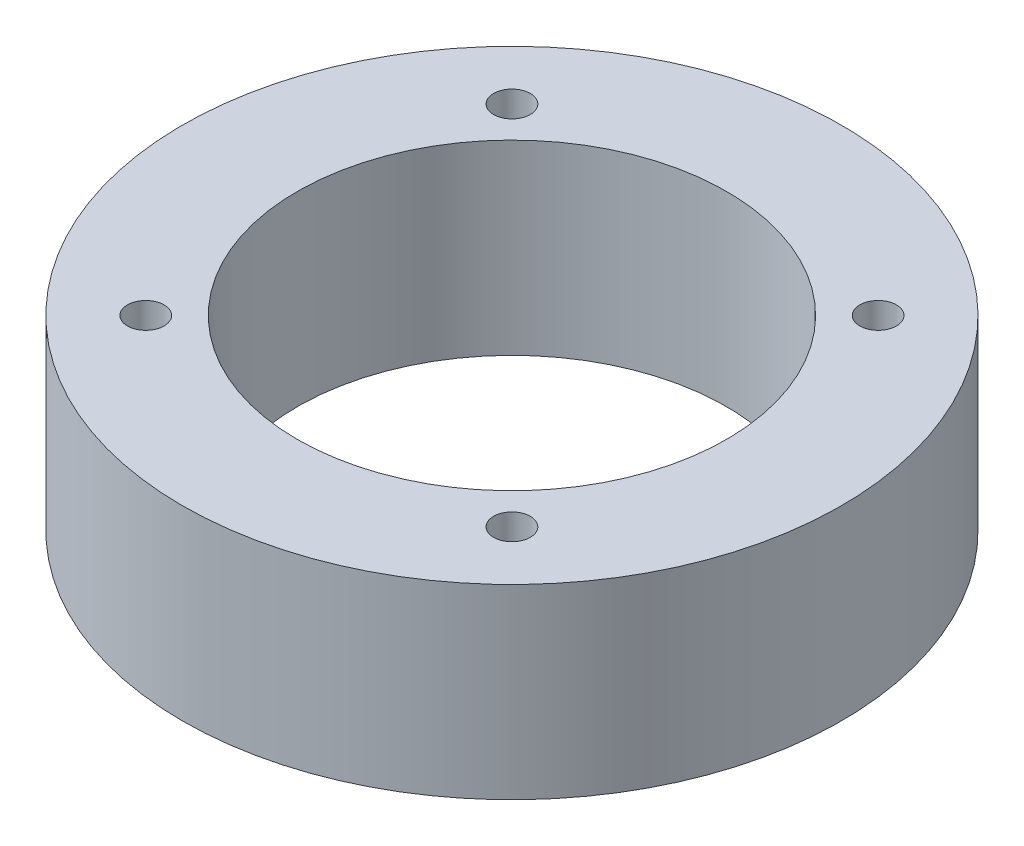
from build123d import *

# Parameters (mm, degrees)
SKETCH1_R           = 25.146
BOSS_EXTRUDE1_DEPTH = 14.224
CUT_EXTRUDE1_REACH  = 16.224
SKETCH2_R           = 1.397
CUT_EXTRUDE2_REACH  = 16.224
SKETCH3_R           = 16.383


with BuildPart() as part:
    # Sketch1 → Boss-Extrude1 (new body)
    with BuildSketch(Plane(origin=(0, 0, 0), x_dir=(1, 0, 0), z_dir=(0, 1, 0))):
        Circle(SKETCH1_R)
    extrude(amount=BOSS_EXTRUDE1_DEPTH)

    # Sketch2 → Cut-Extrude1 (cut, up to next)
    with BuildSketch(Plane(origin=(0, 14.224, 0), x_dir=(1, 0, 0), z_dir=(0, 1, 0)), mode=Mode.PRIVATE) as cut_extrude1_sk1:
        with Locations((13.97, 13.97)):
            Circle(SKETCH2_R)
    cut_extrude1_tool1 = extrude(cut_extrude1_sk1.sketch, amount=-CUT_EXTRUDE1_REACH, mode=Mode.PRIVATE) & part.part
    add(cut_extrude1_tool1.solids().sort_by_distance((13.97, 14.224, -13.97))[0], mode=Mode.SUBTRACT)
    # Sketch2 → Cut-Extrude1 (cut, up to next)
    with BuildSketch(Plane(origin=(0, 14.224, 0), x_dir=(1, 0, 0), z_dir=(0, 1, 0)), mode=Mode.PRIVATE) as cut_extrude1_sk2:
        with Locations((13.97, -13.97)):
            Circle(SKETCH2_R)
    cut_extrude1_tool2 = extrude(cut_extrude1_sk2.sketch, amount=-CUT_EXTRUDE1_REACH, mode=Mode.PRIVATE) & part.part
    add(cut_extrude1_tool2.solids().sort_by_distance((13.97, 14.224, 13.97))[0], mode=Mode.SUBTRACT)
    # Sketch2 → Cut-Extrude1 (cut, up to next)
    with BuildSketch(Plane(origin=(0, 14.224, 0), x_dir=(1, 0, 0), z_dir=(0, 1, 0)), mode=Mode.PRIVATE) as cut_extrude1_sk3:
        with Locations((-13.97, -13.97)):
            Circle(SKETCH2_R)
    cut_extrude1_tool3 = extrude(cut_extrude1_sk3.sketch, amount=-CUT_EXTRUDE1_REACH, mode=Mode.PRIVATE) & part.part
    add(cut_extrude1_tool3.solids().sort_by_distance((-13.97, 14.224, 13.97))[0], mode=Mode.SUBTRACT)
    # Sketch2 → Cut-Extrude1 (cut, up to next)
    with BuildSketch(Plane(origin=(0, 14.224, 0), x_dir=(1, 0, 0), z_dir=(0, 1, 0)), mode=Mode.PRIVATE) as cut_extrude1_sk4:
        with Locations((-13.97, 13.97)):
            Circle(SKETCH2_R)
    cut_extrude1_tool4 = extrude(cut_extrude1_sk4.sketch, amount=-CUT_EXTRUDE1_REACH, mode=Mode.PRIVATE) & part.part
    add(cut_extrude1_tool4.solids().sort_by_distance((-13.97, 14.224, -13.97))[0], mode=Mode.SUBTRACT)

    # Sketch3 → Cut-Extrude2 (cut, up to next)
    with BuildSketch(Plane(origin=(0, 14.224, 0), x_dir=(1, 0, 0), z_dir=(0, 1, 0)), mode=Mode.PRIVATE) as cut_extrude2_sk1:
        Circle(SKETCH3_R)
    cut_extrude2_tool1 = extrude(cut_extrude2_sk1.sketch, amount=-CUT_EXTRUDE2_REACH, mode=Mode.PRIVATE) & part.part
    add(cut_extrude2_tool1.solids().sort_by_distance((0, 14.224, 0))[0], mode=Mode.SUBTRACT)


solid = part.part
